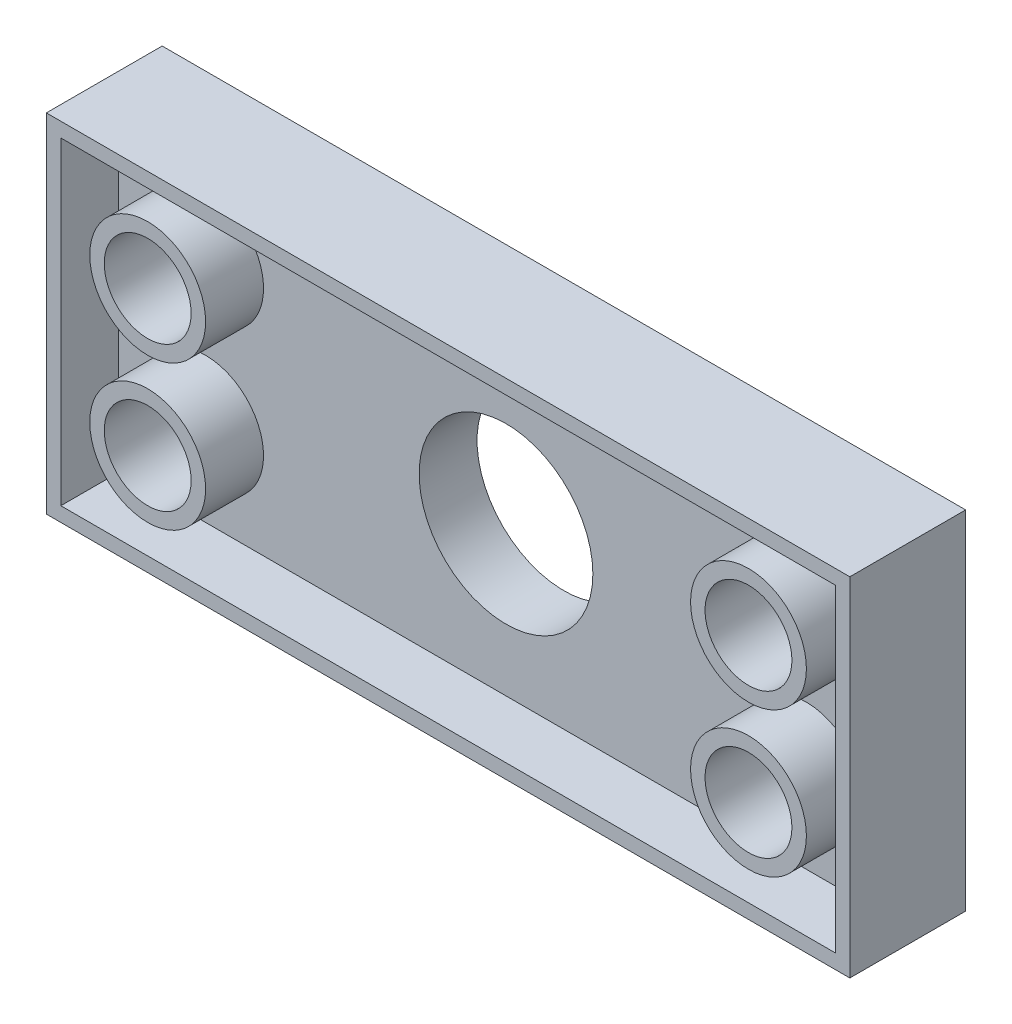
from build123d import *

# Parameters (mm, degrees)
SKETCH1_W           = 169.85
SKETCH1_H           = 69.85
SKETCH1_R           = 9.525
SKETCH1_R_2         = 19.05
BOSS_EXTRUDE1_DEPTH = 12.7
SKETCH2_R           = 12.7
SKETCH2_R_2         = 9.525
BOSS_EXTRUDE2_DEPTH = 12.7
SKETCH3_W           = 176.2
SKETCH3_H           = 76.2
SKETCH3_W_2         = 169.85
SKETCH3_H_2         = 69.85
BOSS_EXTRUDE3_DEPTH = 25.4


with BuildPart() as part:
    # Sketch1 → Boss-Extrude1 (new body)
    with BuildSketch(Plane.XY):
        with Locations((46.032710784, 129.625650191)):
            Rectangle(SKETCH1_W, SKETCH1_H)
        with Locations((-19.842289216, 145.500650191)):
            Circle(SKETCH1_R, mode=Mode.SUBTRACT)
        with Locations((-19.842289216, 113.750650191)):
            Circle(SKETCH1_R, mode=Mode.SUBTRACT)
        with Locations((111.907710784, 145.500650191)):
            Circle(SKETCH1_R, mode=Mode.SUBTRACT)
        with Locations((111.907710784, 113.750650191)):
            Circle(SKETCH1_R, mode=Mode.SUBTRACT)
        with Locations((46.032710784, 127.370341001)):
            Circle(SKETCH1_R_2, mode=Mode.SUBTRACT)
    extrude(amount=BOSS_EXTRUDE1_DEPTH)

    # Sketch2 → Boss-Extrude2 (add)
    with BuildSketch(Plane.XY.offset(12.7)):
        with Locations((111.907710784, 145.500650191)):
            Circle(SKETCH2_R)
        with Locations((111.907710784, 145.500650191)):
            Circle(SKETCH2_R_2, mode=Mode.SUBTRACT)
        with Locations((111.907710784, 113.750650191)):
            Circle(SKETCH2_R)
        with Locations((111.907710784, 113.750650191)):
            Circle(SKETCH2_R_2, mode=Mode.SUBTRACT)
        with Locations((-19.842289216, 113.750650191)):
            Circle(SKETCH2_R)
        with Locations((-19.842289216, 113.750650191)):
            Circle(SKETCH2_R_2, mode=Mode.SUBTRACT)
        with Locations((-19.842289216, 145.500650191)):
            Circle(SKETCH2_R)
        with Locations((-19.842289216, 145.500650191)):
            Circle(SKETCH2_R_2, mode=Mode.SUBTRACT)
    extrude(amount=BOSS_EXTRUDE2_DEPTH)

    # Sketch3 → Boss-Extrude3 (add)
    with BuildSketch(Plane(origin=(0, 0, 0), x_dir=(-1, 0, 0), z_dir=(0, 0, -1))):
        with Locations((-46.032710784, 129.625650191)):
            Rectangle(SKETCH3_W, SKETCH3_H)
        with Locations((-46.032710784, 129.625650191)):
            Rectangle(SKETCH3_W_2, SKETCH3_H_2, mode=Mode.SUBTRACT)
    extrude(amount=-BOSS_EXTRUDE3_DEPTH)


solid = part.part
